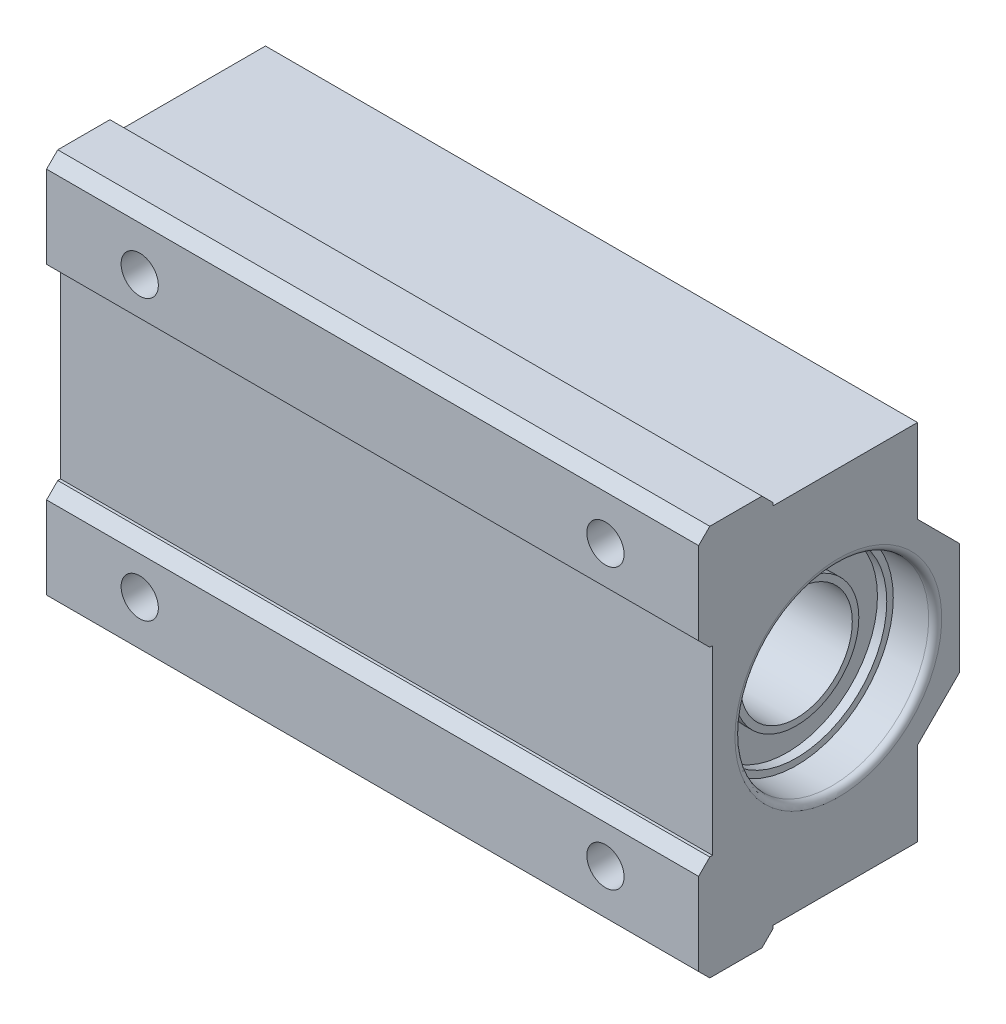
from build123d import *

# Parameters (mm, degrees)
CROQUIS1_W              = 70
CROQUIS1_H              = 42
SALIENTE_EXTRUIR1_DEPTH = 28
CROQUIS2_W              = 1.5
CROQUIS2_H              = 19.5
CORTAR_EXTRUIR1_DEPTH   = 70
CROQUIS3_R              = 2
CORTAR_EXTRUIR2_DEPTH   = 70
CROQUIS4_R              = 6
CORTAR_EXTRUIR3_DEPTH   = 70
CROQUIS5_R              = 10.4
CORTAR_EXTRUIR4_DEPTH   = 4.5
CROQUIS6_R              = 9.7
CROQUIS6_R_2            = 6.7
CORTAR_EXTRUIR5_DEPTH   = 1
CHAFL_N1_SIZE           = 1.2
REDONDEO1_R             = 0.7


with BuildPart() as part:
    # Croquis1 → Saliente-Extruir1 (new body)
    with BuildSketch(Plane.XY):
        Rectangle(CROQUIS1_W, CROQUIS1_H)
    extrude(amount=SALIENTE_EXTRUIR1_DEPTH)

    # Croquis2 → Cortar-Extruir1 (cut)
    with BuildSketch(Plane(origin=(35, 0, 0), x_dir=(0, 0, -1), z_dir=(1, 0, 0))):
        with Locations((-27.25, 0)):
            Rectangle(CROQUIS2_W, CROQUIS2_H)
        Polygon((0, 21), (-20, 21), (-20, 19.5), (-4.5, 19.5), (-4.5, 10.5), (0, 6), align=None)
        Polygon((-20, -19.5), (-20, -21), (0, -21), (0, -6), (-4.5, -10.5), (-4.5, -19.5), align=None)
    extrude(amount=-CORTAR_EXTRUIR1_DEPTH, mode=Mode.SUBTRACT)

    # Croquis3 → Cortar-Extruir2 (cut)
    with BuildSketch(Plane.XY.offset(28)):
        with Locations((25, -15)):
            Circle(CROQUIS3_R)
        with Locations((-25, -15)):
            Circle(CROQUIS3_R)
        with Locations((-25, 15)):
            Circle(CROQUIS3_R)
        with Locations((25, 15)):
            Circle(CROQUIS3_R)
    extrude(amount=-CORTAR_EXTRUIR2_DEPTH, mode=Mode.SUBTRACT)

    # Croquis4 → Cortar-Extruir3 (cut)
    with BuildSketch(Plane(origin=(35, 0, 0), x_dir=(0, 0, -1), z_dir=(1, 0, 0))):
        with Locations((-13, 0)):
            Circle(CROQUIS4_R)
    extrude(amount=-CORTAR_EXTRUIR3_DEPTH, mode=Mode.SUBTRACT)

    # Croquis5 → Cortar-Extruir4 (cut)
    with BuildSketch(Plane(origin=(35, 0, 0), x_dir=(0, 0, -1), z_dir=(1, 0, 0))):
        with Locations((-13, 0)):
            Circle(CROQUIS5_R)
    cortar_extruir4 = extrude(amount=-CORTAR_EXTRUIR4_DEPTH, mode=Mode.SUBTRACT)

    # Croquis6 → Cortar-Extruir5 (cut)
    with BuildSketch(Plane(origin=(30.5, 0, 0), x_dir=(0, 0, -1), z_dir=(1, 0, 0))):
        with Locations((-13, 0)):
            Circle(CROQUIS6_R)
        with Locations((-13, 0)):
            Circle(CROQUIS6_R_2, mode=Mode.SUBTRACT)
    cortar_extruir5 = extrude(amount=-CORTAR_EXTRUIR5_DEPTH, mode=Mode.SUBTRACT)

    # Simetría1: Cortar-Extruir4, Cortar-Extruir5 across plane
    add(cortar_extruir4.mirror(Plane(origin=(0, 0, 0), x_dir=(0, 0, 1), z_dir=(1, 0, 0))), mode=Mode.SUBTRACT)
    add(cortar_extruir5.mirror(Plane(origin=(0, 0, 0), x_dir=(0, 0, 1), z_dir=(1, 0, 0))), mode=Mode.SUBTRACT)

    # Chaflán1
    chafl_n1_edges = [part.edges().sort_by_distance(p)[0] for p in [
        (0, -21, 28),
        (0, -9.75, 28),
        (0, 9.75, 28),
        (0, 21, 20),
        (0, -21, 20),
        (0, 21, 28),
    ]]
    chamfer(chafl_n1_edges, length=CHAFL_N1_SIZE)

    # Redondeo1
    redondeo1_edges = [part.edges().sort_by_distance(p)[0] for p in [
        (-35, 0, 23.4),
        (35, 0, 23.4),
    ]]
    fillet(redondeo1_edges, radius=REDONDEO1_R)


solid = part.part
